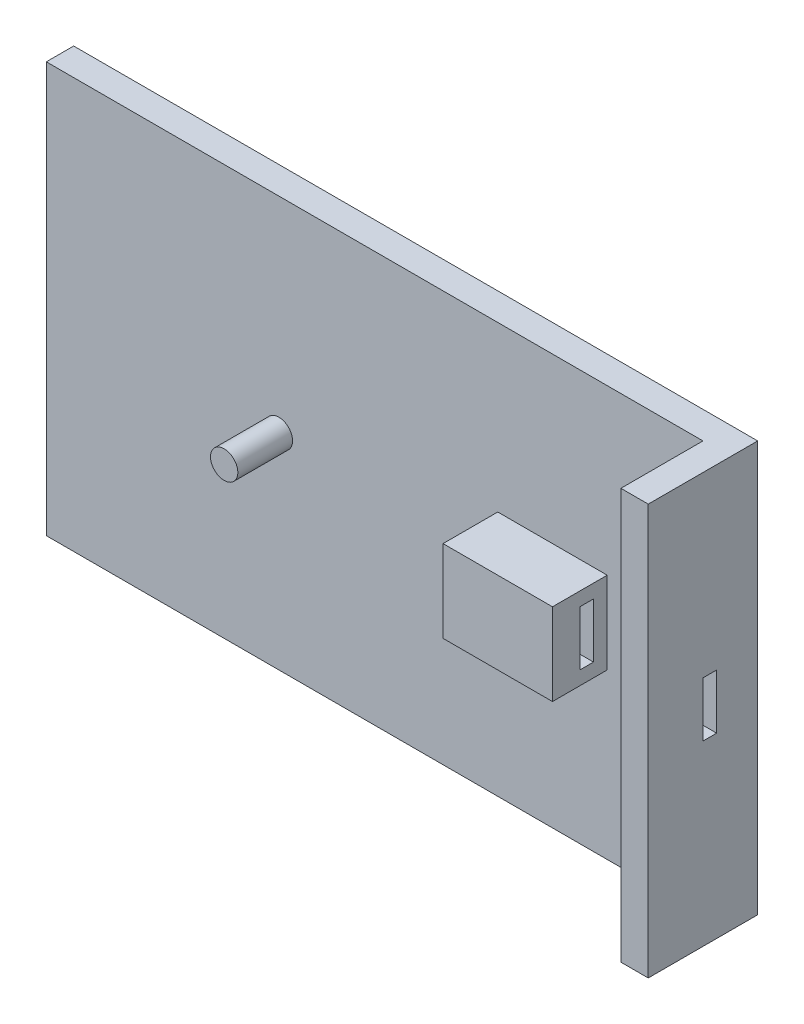
from build123d import *

# Parameters (mm, degrees)
SKETCH1_W           = 250
SKETCH1_H           = 150
SKETCH1_R           = 5
SKETCH1_W_2         = 40
SKETCH1_H_2         = 5
BOSS_EXTRUDE1_DEPTH = 10
SKETCH1_5_W         = 10
SKETCH1_5_H         = 150
BOSS_EXTRUDE2_DEPTH = 40
SKETCH1_6_R         = 5
BOSS_EXTRUDE3_DEPTH = 30
SKETCH1_7_W         = 40
SKETCH1_7_H         = 5
BOSS_EXTRUDE4_DEPTH = 30
SKETCH6_W           = 5
SKETCH6_H           = 20
SKETCH6_W_2         = 10
SKETCH6_H_2         = 20.218770798
BOSS_EXTRUDE5_DEPTH = 40
SKETCH7_W           = 5
SKETCH7_H           = 20
CUT_EXTRUDE1_DEPTH  = 10


with BuildPart() as part:
    # Sketch1 → Boss-Extrude1 (new body)
    with BuildSketch(Plane.XY):
        Rectangle(SKETCH1_W, SKETCH1_H)
        with Locations((-40, 0)):
            Circle(SKETCH1_R, mode=Mode.SUBTRACT)
        with Locations((60, -12.5)):
            Rectangle(SKETCH1_W_2, SKETCH1_H_2, mode=Mode.SUBTRACT)
        with Locations((60, 12.5)):
            Rectangle(SKETCH1_W_2, SKETCH1_H_2, mode=Mode.SUBTRACT)
    extrude(amount=BOSS_EXTRUDE1_DEPTH)

    # Sketch1_5 → Boss-Extrude2 (add)
    with BuildSketch(Plane.XY):
        with Locations((120, 0)):
            Rectangle(SKETCH1_5_W, SKETCH1_5_H)
    extrude(amount=BOSS_EXTRUDE2_DEPTH)

    # Sketch1_6 → Boss-Extrude3 (add)
    with BuildSketch(Plane.XY):
        with Locations((-40, 0)):
            Circle(SKETCH1_6_R)
    extrude(amount=BOSS_EXTRUDE3_DEPTH)

    # Sketch1_7 → Boss-Extrude4 (add)
    with BuildSketch(Plane.XY):
        with Locations((60, -12.5)):
            Rectangle(SKETCH1_7_W, SKETCH1_7_H)
        with Locations((60, 12.5)):
            Rectangle(SKETCH1_7_W, SKETCH1_7_H)
    extrude(amount=BOSS_EXTRUDE4_DEPTH)

    # Sketch6 → Boss-Extrude5 (add)
    with BuildSketch(Plane.ZY.offset(-40)):
        with Locations((12.5, 0)):
            Rectangle(SKETCH6_W, SKETCH6_H)
        with Locations((25, -0.109385399)):
            Rectangle(SKETCH6_W_2, SKETCH6_H_2)
    extrude(amount=-BOSS_EXTRUDE5_DEPTH)

    # Sketch7 → Cut-Extrude1 (cut)
    with BuildSketch(Plane.ZY.offset(-115)):
        with Locations((17.5, 0)):
            Rectangle(SKETCH7_W, SKETCH7_H)
    extrude(amount=-CUT_EXTRUDE1_DEPTH, mode=Mode.SUBTRACT)


solid = part.part
